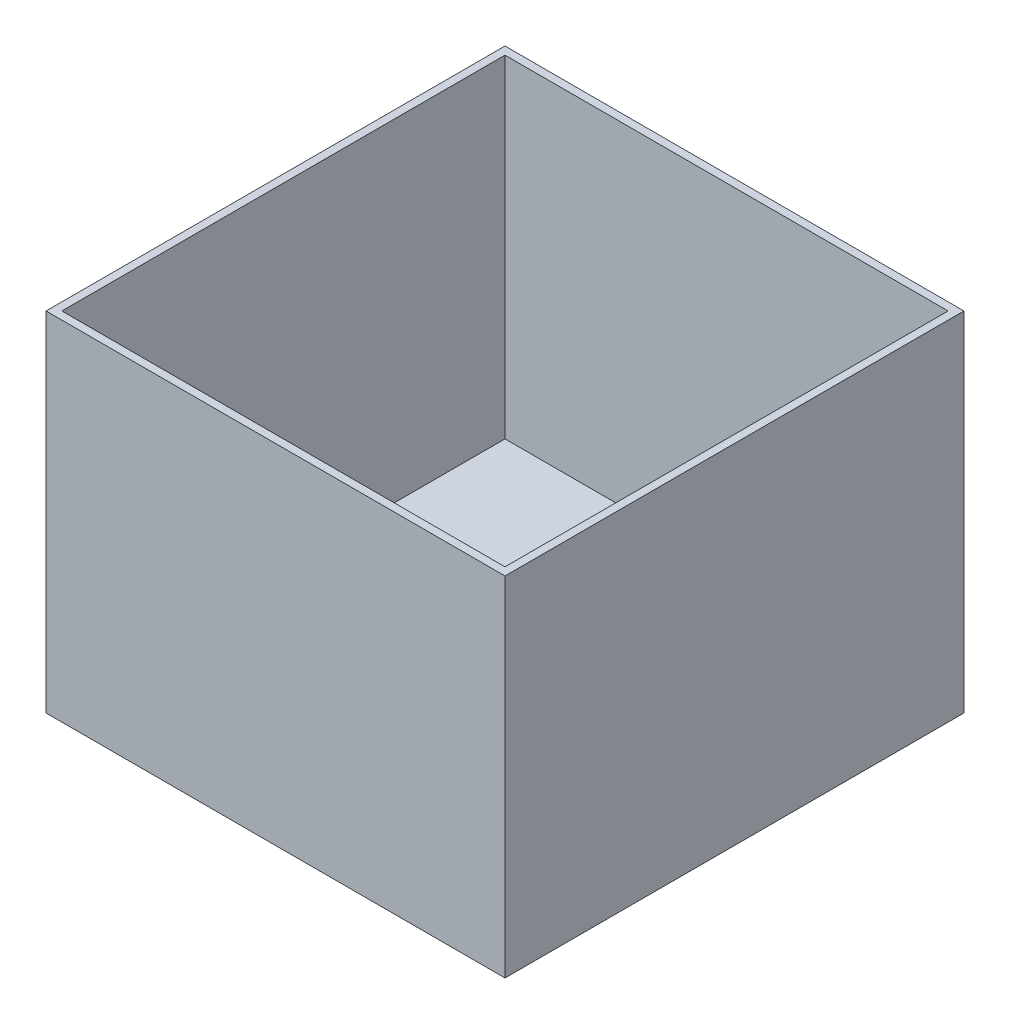
from build123d import *

# Parameters (mm, degrees)
SKETCH1_W           = 184.15
SKETCH1_H           = 184.15
BOSS_EXTRUDE1_DEPTH = 139.7
SKETCH2_W           = 177.8
SKETCH2_H           = 177.8
CUT_EXTRUDE1_DEPTH  = 133.35
SKETCH3_R           = 5.842
BOSS_EXTRUDE2_DEPTH = 6.604


with BuildPart() as part:
    # Sketch1 → Boss-Extrude1 (new body)
    with BuildSketch(Plane(origin=(0, 0, 0), x_dir=(1, 0, 0), z_dir=(0, 1, 0))):
        Rectangle(SKETCH1_W, SKETCH1_H)
    extrude(amount=BOSS_EXTRUDE1_DEPTH)

    # Sketch2 → Cut-Extrude1 (cut)
    with BuildSketch(Plane(origin=(0, 139.7, 0), x_dir=(1, 0, 0), z_dir=(0, 1, 0))):
        Rectangle(SKETCH2_W, SKETCH2_H)
    extrude(amount=-CUT_EXTRUDE1_DEPTH, mode=Mode.SUBTRACT)

    # Sketch3 → Boss-Extrude2 (add)
    with BuildSketch(Plane(origin=(0, 6.35, 0), x_dir=(1, 0, 0), z_dir=(0, 1, 0))):
        with Locations((-1.016, 78.651394374)):
            Circle(SKETCH3_R)
    extrude(amount=BOSS_EXTRUDE2_DEPTH)


solid = part.part
